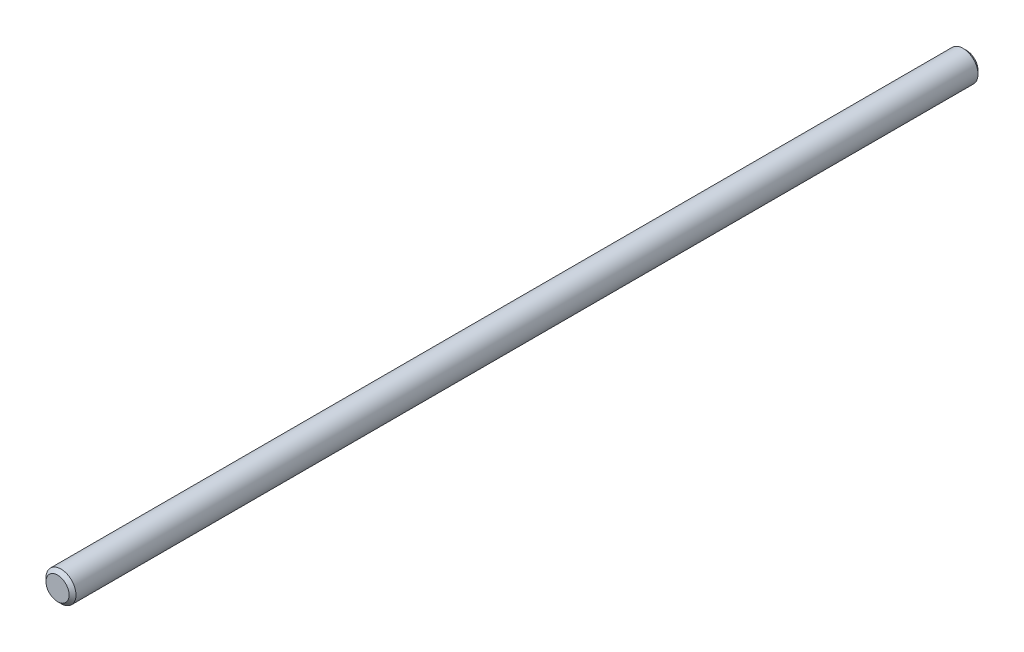
from build123d import *

# Parameters (mm, degrees)
SKETCH1_R           = 13
BOSS_EXTRUDE1_DEPTH = 787.5
CHAMFER1_SIZE       = 3


with BuildPart() as part:
    # Sketch1 → Boss-Extrude1 (new body)
    with BuildSketch(Plane.XY):
        Circle(SKETCH1_R)
    extrude(amount=BOSS_EXTRUDE1_DEPTH)

    # Chamfer1
    chamfer1_edges = [part.edges().sort_by_distance(p)[0] for p in [
        (-13, 0, 0),
        (-13, 0, 787.5),
    ]]
    chamfer(chamfer1_edges, length=CHAMFER1_SIZE)


solid = part.part
